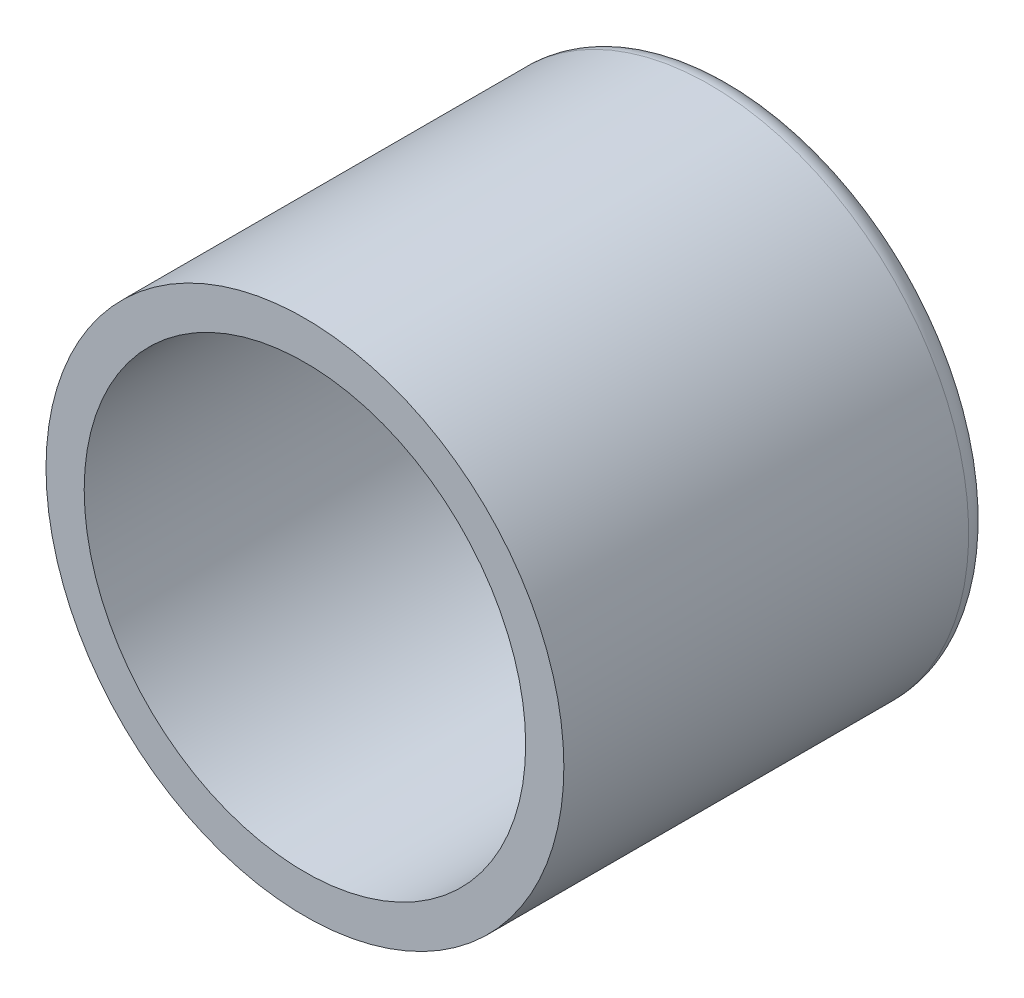
from build123d import *

# Parameters (mm, degrees)
SKETCH1_R           = 16.95
SKETCH1_R_2         = 14.45
BOSS_EXTRUDE1_DEPTH = 25
SKETCH2_R           = 16.95
BOSS_EXTRUDE2_DEPTH = 3
FILLET1_R           = 1.5


with BuildPart() as part:
    # Sketch1 → Boss-Extrude1 (new body)
    with BuildSketch(Plane.XY):
        Circle(SKETCH1_R)
        Circle(SKETCH1_R_2, mode=Mode.SUBTRACT)
    extrude(amount=BOSS_EXTRUDE1_DEPTH)

    # Sketch2 → Boss-Extrude2 (add)
    with BuildSketch(Plane(origin=(0, 0, 0), x_dir=(-1, 0, 0), z_dir=(0, 0, -1))):
        Circle(SKETCH2_R)
    extrude(amount=BOSS_EXTRUDE2_DEPTH)

    # Fillet1
    fillet1_edges = [part.edges().sort_by_distance(p)[0] for p in [
        (16.95, 0, -3),
    ]]
    fillet(fillet1_edges, radius=FILLET1_R)


solid = part.part
